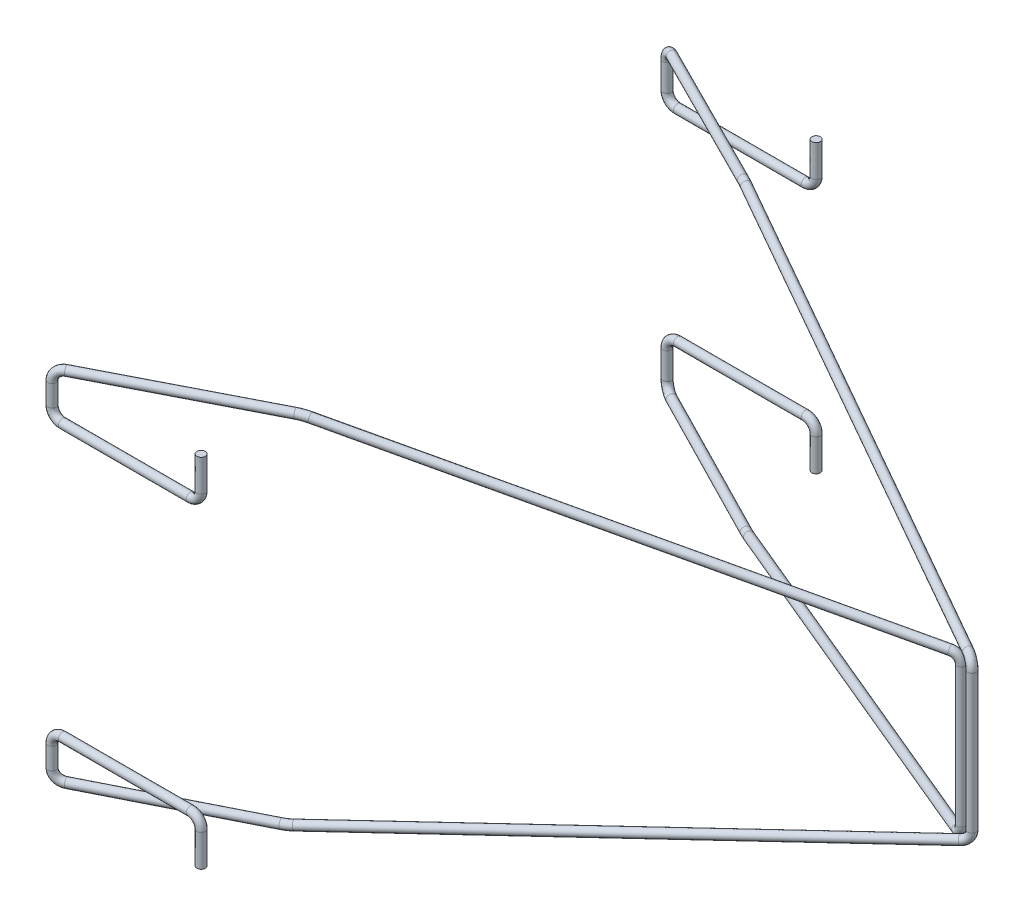
from build123d import *

# Parameters (mm, degrees)
SKETCH9_R  = 0.4
SKETCH10_R = 0.4
SKETCH11_R = 0.4
SKETCH12_R = 0.4
SKETCH15_R = 0.4
SKETCH16_R = 0.4
SKETCH17_R = 0.4
SKETCH18_R = 0.4


with BuildPart() as part:
    # Sweep1: sweep along a path in Sketch7
    with BuildLine(Plane(origin=(-48.501568058, 0, -94.92811354), x_dir=(-0.890500232, 0, 0.454982787), z_dir=(-0.454982787, 0, -0.890500232))) as sweep1_path:
        ThreePointArc((-46.604780717, 15.749022113), (-46.897673935, 16.456128895), (-47.604780717, 16.749022113))
        Line((-47.604780717, 16.749022113), (-63.604780717, 16.749022113))
        ThreePointArc((-63.604780717, 16.749022113), (-64.110243737, 16.723407215), (-64.610527804, 16.646824968))
        Line((-64.610527804, 16.646824968), (-109.25341498, 7.479560571))
        ThreePointArc((-109.25341498, 7.479560571), (-109.827233116, 7.132001022), (-110.052265563, 6.5))
    # Sketch9 → Sweep1 (sweep)
    with BuildSketch(Plane(origin=(0, 6.5, 0), x_dir=(-1, 0, 0), z_dir=(0, 1, 0))):
        with Locations((-49.5, -145)):
            Circle(SKETCH9_R)
    sweep(path=sweep1_path.line)

    # Sweep2: sweep along a path in Sketch3
    with BuildLine(Plane.XY.offset(-116.132486541)) as sweep2_path:
        Line((7, 16.749022113), (7, 13.749022113))
        ThreePointArc((7, 13.749022113), (6.707106781, 13.041915332), (6, 12.749022113))
        Line((6, 12.749022113), (-6, 12.749022113))
        ThreePointArc((-6, 12.749022113), (-6.707106781, 13.041915332), (-7, 13.749022113))
        Line((-7, 13.749022113), (-7, 15.749022113))
    # Sketch10 → Sweep2 (sweep)
    with BuildSketch(Plane.XZ.offset(-15.749022113)):
        with Locations((-7, -116.132486541)):
            Circle(SKETCH10_R)
    sweep(path=sweep2_path.line)

    # Sweep3: sweep along a path in Sketch8
    with BuildLine(Plane(origin=(68.995492334, 0, -135.039178985), x_dir=(-0.890500232, 0, -0.454982787), z_dir=(0.454982787, 0, -0.890500232))) as sweep3_path:
        Line((21.892742557, 6.5), (21.892742557, -6.5))
        ThreePointArc((21.892742557, -6.5), (22.137188299, -7.155086073), (22.751018082, -7.489906144))
        Line((22.751018082, -7.489906144), (67.63160503, -13.915442191))
        ThreePointArc((67.63160503, -13.915442191), (67.985018726, -13.953278193), (68.340227403, -13.965911473))
        Line((68.340227403, -13.965911473), (84.340227403, -13.965911473))
        ThreePointArc((84.340227403, -13.965911473), (85.047334184, -13.673018254), (85.340227403, -12.965911473))
    # Sketch11 → Sweep3 (sweep)
    with BuildSketch(Plane.XZ.offset(-6.5)):
        with Locations((49.5, -145)):
            Circle(SKETCH11_R)
    sweep(path=sweep3_path.line)

    # Sweep5: sweep along a path in Sketch6
    with BuildLine(Plane.XY.offset(-173.867513459)) as sweep5_path:
        Line((7, -13.465911473), (7, -10.465911473))
        ThreePointArc((7, -10.465911473), (6.707106781, -9.758804692), (6, -9.465911473))
        Line((6, -9.465911473), (-6, -9.465911473))
        ThreePointArc((-6, -9.465911473), (-6.707106781, -9.758804692), (-7, -10.465911473))
        Line((-7, -10.465911473), (-7, -12.965911473))
    # Sketch12 → Sweep5 (sweep)
    with BuildSketch(Plane(origin=(0, -12.965911473, 0), x_dir=(-1, 0, 0), z_dir=(0, 1, 0))):
        with Locations((7, -173.867513459)):
            Circle(SKETCH12_R)
    sweep(path=sweep5_path.line)

    # Sweep6: sweep along a path in Sketch14
    with BuildLine(Plane(origin=(68.307895755, 0, -136.059657906), x_dir=(-0.893695415, 0, -0.448674164), z_dir=(0.448674164, 0, -0.893695415))) as sweep6_path:
        ThreePointArc((84.265729123, 12.965911473), (83.972835904, 13.673018254), (83.265729123, 13.965911473))
        Line((83.265729123, 13.965911473), (68.265729123, 13.965911473))
        ThreePointArc((68.265729123, 13.965911473), (67.924682333, 13.954266622), (67.58522412, 13.919386308))
        Line((67.58522412, 13.919386308), (20.790034299, 7.490694967))
        ThreePointArc((20.790034299, 7.490694967), (20.172444049, 7.157228651), (19.926135299, 6.5))
    # Sketch15 → Sweep6 (sweep)
    with BuildSketch(Plane(origin=(0, 6.5, 0), x_dir=(-1, 0, 0), z_dir=(0, 1, 0))):
        with Locations((-50.5, -145)):
            Circle(SKETCH15_R)
    sweep(path=sweep6_path.line)

    # Sweep7: sweep along a path in Sketch4
    with BuildLine(Plane.XY.offset(-173.867513459)) as sweep7_path:
        Line((7, 13.465911473), (7, 10.465911473))
        ThreePointArc((7, 10.465911473), (6.707106781, 9.758804692), (6, 9.465911473))
        Line((6, 9.465911473), (-6, 9.465911473))
        ThreePointArc((-6, 9.465911473), (-6.707106781, 9.758804692), (-7, 10.465911473))
        Line((-7, 10.465911473), (-7, 12.965911473))
    # Sketch16 → Sweep7 (sweep)
    with BuildSketch(Plane.XZ.offset(-12.965911473)):
        with Locations((-7, -173.867513459)):
            Circle(SKETCH16_R)
    sweep(path=sweep7_path.line)

    # Sweep8: sweep along a path in Sketch13
    with BuildLine(Plane(origin=(-47.975736721, 0, -95.560875561), x_dir=(-0.893695415, 0, 0.448674164), z_dir=(-0.448674164, 0, -0.893695415))) as sweep8_path:
        Line((-110.18937221, 6.5), (-110.18937221, -6.5))
        ThreePointArc((-110.18937221, -6.5), (-109.961798623, -7.135104273), (-109.382657336, -7.48114263))
        Line((-109.382657336, -7.48114263), (-62.816204017, -16.654735263))
        ThreePointArc((-62.816204017, -16.654735263), (-62.335285469, -16.725394575), (-61.849778387, -16.749022113))
        Line((-61.849778387, -16.749022113), (-46.849778387, -16.749022113))
        ThreePointArc((-46.849778387, -16.749022113), (-46.142671606, -16.456128895), (-45.849778387, -15.749022113))
    # Sketch17 → Sweep8 (sweep)
    with BuildSketch(Plane.XZ.offset(-6.5)):
        with Locations((50.5, -145)):
            Circle(SKETCH17_R)
    sweep(path=sweep8_path.line)

    # Sweep9: sweep along a path in Sketch5
    with BuildLine(Plane.XY.offset(-116.132486541)) as sweep9_path:
        Line((7, -16.749022113), (7, -13.749022113))
        ThreePointArc((7, -13.749022113), (6.707106781, -13.041915332), (6, -12.749022113))
        Line((6, -12.749022113), (-6, -12.749022113))
        ThreePointArc((-6, -12.749022113), (-6.707106781, -13.041915332), (-7, -13.749022113))
        Line((-7, -13.749022113), (-7, -15.749022113))
    # Sketch18 → Sweep9 (sweep)
    with BuildSketch(Plane(origin=(0, -15.749022113, 0), x_dir=(-1, 0, 0), z_dir=(0, 1, 0))):
        with Locations((7, -116.132486541)):
            Circle(SKETCH18_R)
    sweep(path=sweep9_path.line)


solid = part.part
